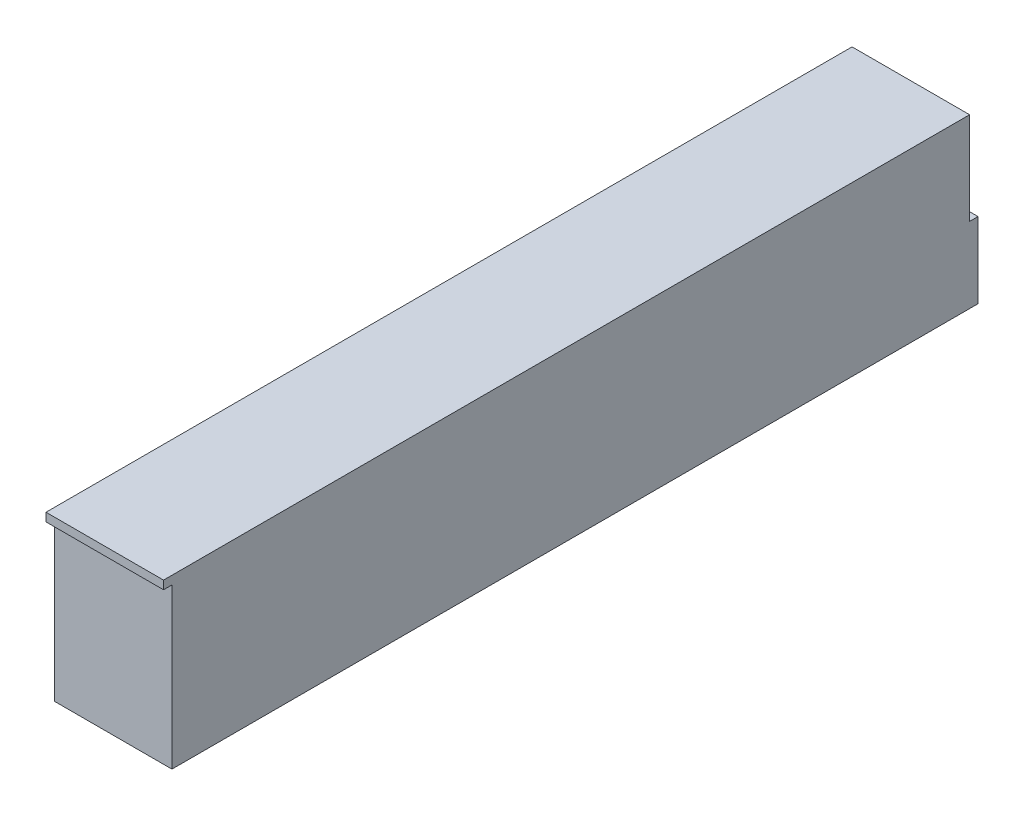
from build123d import *

# Parameters (mm, degrees)
SKETCH1_W           = 22.225
SKETCH1_H           = 152.4
BOSS_EXTRUDE1_DEPTH = 31.75
SKETCH2_W           = 1.5875
SKETCH2_H           = 30.1625
CUT_EXTRUDE1_DEPTH  = 23.225
SKETCH3_W           = 1.5875
SKETCH3_H           = 14.2875
BOSS_EXTRUDE2_DEPTH = 22.225


with BuildPart() as part:
    # Sketch1 → Boss-Extrude1 (new body)
    with BuildSketch(Plane(origin=(0, 0, 0), x_dir=(1, 0, 0), z_dir=(0, 1, 0))):
        with Locations((11.1125, 76.2)):
            Rectangle(SKETCH1_W, SKETCH1_H)
    extrude(amount=BOSS_EXTRUDE1_DEPTH)

    # Sketch2 → Cut-Extrude1 (cut, through all)
    with BuildSketch(Plane(origin=(22.225, 0, 0), x_dir=(0, 0, -1), z_dir=(1, 0, 0))):
        with Locations((0.79375, 15.08125)):
            Rectangle(SKETCH2_W, SKETCH2_H)
    extrude(amount=-CUT_EXTRUDE1_DEPTH, mode=Mode.SUBTRACT)

    # Sketch3 → Boss-Extrude2 (add)
    with BuildSketch(Plane(origin=(22.225, 0, 0), x_dir=(0, 0, -1), z_dir=(1, 0, 0))):
        with Locations((153.19375, 7.14375)):
            Rectangle(SKETCH3_W, SKETCH3_H)
    extrude(amount=-BOSS_EXTRUDE2_DEPTH)


solid = part.part
